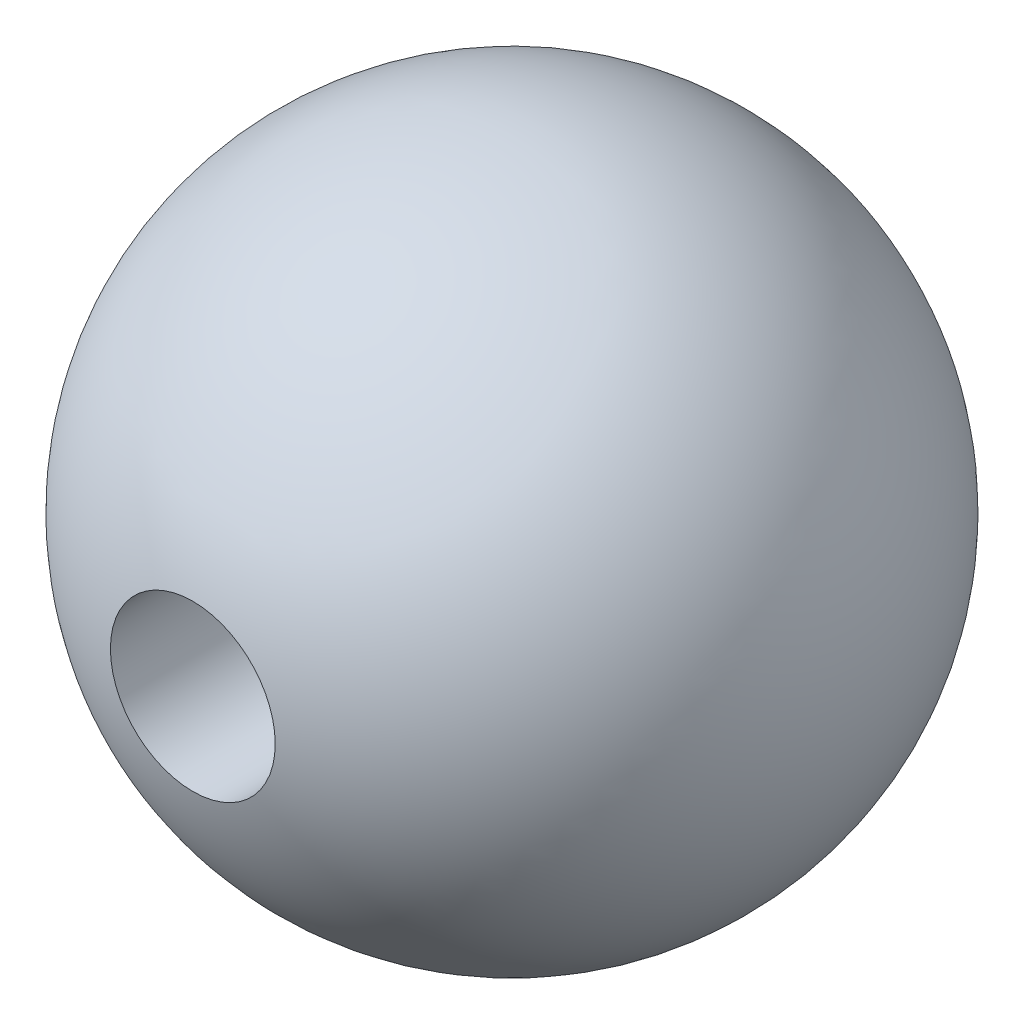
from build123d import *


with BuildPart() as part:
    # Sketch2 → Revolve1 (revolve)
    with BuildSketch(Plane(origin=(0, 0, 0), x_dir=(0, 0, -1), z_dir=(1, 0, 0))):
        with BuildLine():
            Line((12.498361062, 0), (0.201638938, 0))
            Line((0.201638938, 0), (0.201638938, 3.175))
            Line((0.201638938, 3.175), (-12.498361062, 3.175))
            ThreePointArc((-12.498361062, 3.175), (1.398615577, 12.598777143), (12.498361062, 0))
        make_face()
    revolve(axis=Axis((0, 0, -12.498361062), (0, 0, 1)))


solid = part.part
